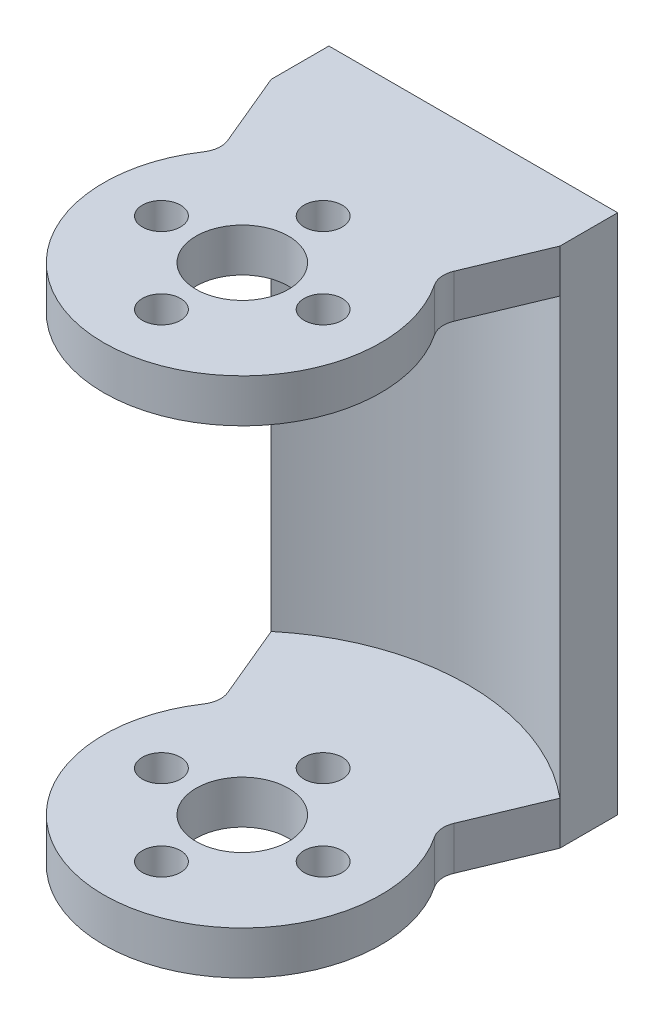
from build123d import *

# Parameters (mm, degrees)
SKETCH1_R           = 4
BOSS_EXTRUDE1_DEPTH = 45.15
SKETCH2_W           = 40
SKETCH2_H           = 37.65
CUT_EXTRUDE1_DEPTH  = 26
SKETCH3_R           = 1.65
CUT_EXTRUDE2_DEPTH  = 46.15
CIRPATTERN1_COUNT   = 4
FILLET1_R           = 2
CUT_EXTRUDE4_DEPTH  = 37.65


with BuildPart() as part:
    # Sketch1 → Boss-Extrude1 (new body)
    with BuildSketch(Plane(origin=(0, 0, 0), x_dir=(1, 0, 0), z_dir=(0, 1, 0))):
        with BuildLine():
            Line((-12.5, 15), (-12.5, 20))
            Line((-12.5, 20), (12.5, 20))
            Line((12.5, 20), (12.5, 15))
            Line((12.5, 15), (9.367496998, 7.5))
            ThreePointArc((9.367496998, 7.5), (0, -12), (-9.367496998, 7.5))
            Line((-9.367496998, 7.5), (-12.5, 15))
        make_face()
        Circle(SKETCH1_R, mode=Mode.SUBTRACT)
    extrude(amount=BOSS_EXTRUDE1_DEPTH)

    # Sketch2 → Cut-Extrude1 (cut, through all)
    with BuildSketch(Plane.ZY.offset(12.5)):
        with Locations((5, 22.575)):
            Rectangle(SKETCH2_W, SKETCH2_H)
    extrude(amount=-CUT_EXTRUDE1_DEPTH, mode=Mode.SUBTRACT)

    # Sketch3 → Cut-Extrude2 (cut, through all)
    with BuildSketch(Plane(origin=(0, 45.15, 0), x_dir=(1, 0, 0), z_dir=(0, 1, 0))):
        with Locations((0, 7)):
            Circle(SKETCH3_R)
    cut_extrude2 = extrude(amount=-CUT_EXTRUDE2_DEPTH, mode=Mode.SUBTRACT)

    # CirPattern1: Cut-Extrude2 ×4 about axis
    cirpattern1_axis = Axis((0, 0, 0), (0, 1, 0))
    for i in range(1, CIRPATTERN1_COUNT):
        add(cut_extrude2.rotate(cirpattern1_axis, i * 360 / CIRPATTERN1_COUNT), mode=Mode.SUBTRACT)

    # Fillet1
    fillet1_edges = [part.edges().sort_by_distance(p)[0] for p in [
        (9.367496998, 43.275, -7.5),
        (-9.367496998, 43.275, -7.5),
        (9.367496998, 1.875, -7.5),
        (-9.367496998, 1.875, -7.5),
    ]]
    fillet(fillet1_edges, radius=FILLET1_R)

    # Sketch4 → Cut-Extrude4 (cut)
    with BuildSketch(Plane(origin=(0, 3.75, 0), x_dir=(1, 0, 0), z_dir=(0, 1, 0))):
        with BuildLine():
            Line((-12.5, 15), (12.5, 15))
            ThreePointArc((12.5, 15), (0, 19.52562419), (-12.5, 15))
        make_face()
    extrude(amount=CUT_EXTRUDE4_DEPTH, mode=Mode.SUBTRACT)


solid = part.part
